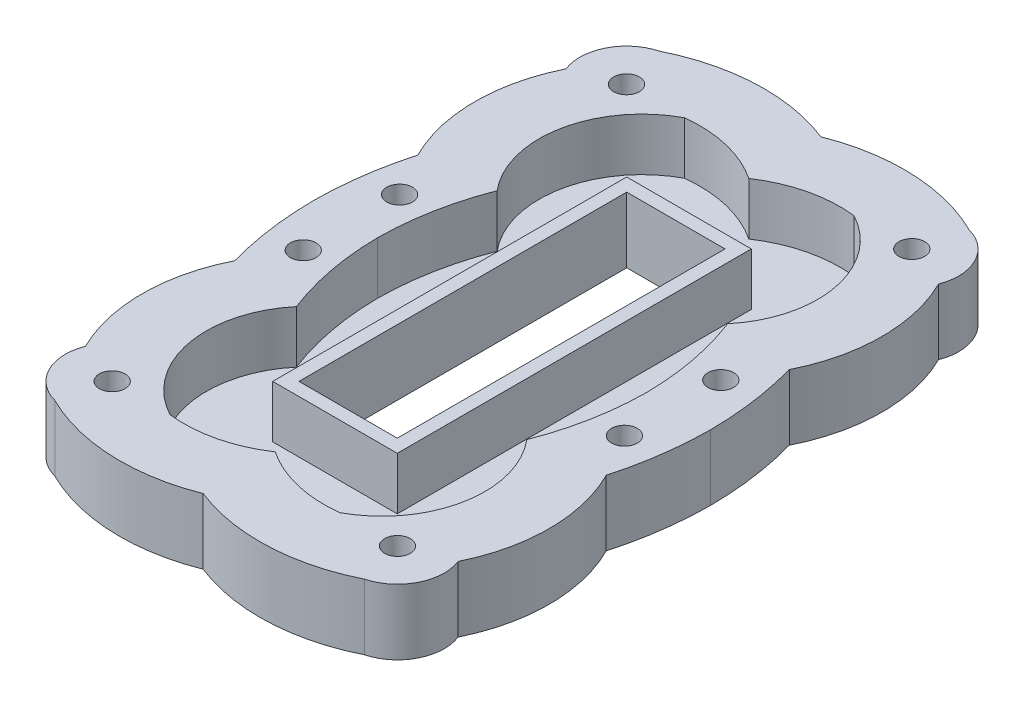
from build123d import *

# Parameters (mm, degrees)
SKETCH1_W           = 19
SKETCH1_H           = 54
BOSS_EXTRUDE4_DEPTH = 2
SKETCH1_8_R         = 1.96
SKETCH1_8_W         = 19
SKETCH1_8_H         = 54
SKETCH1_8_W_2       = 15
SKETCH1_8_H_2       = 50
BOSS_EXTRUDE7_DEPTH = 10


with BuildPart() as part:
    # Sketch1 → Boss-Extrude4 (new body)
    with BuildSketch(Plane(origin=(0, 0, 0), x_dir=(1, 0, 0), z_dir=(0, 1, 0))):
        with BuildLine():
            ThreePointArc((0, 36.123062219), (-6.193274653, 38.828364827), (-12.939793146, 39.228116436))
            ThreePointArc((-12.939793146, 39.228116436), (-20.958488329, 28.375411428), (-17.576524537, 15.31237199))
            ThreePointArc((-17.576524537, 15.31237199), (-19.723741965, 7.787946982), (-20.482290695, 0))
            ThreePointArc((-20.482290695, 0), (-19.723741965, -7.787946982), (-17.576524537, -15.31237199))
            ThreePointArc((-17.576524537, -15.31237199), (-20.958488329, -28.375411428), (-12.939793146, -39.228116436))
            ThreePointArc((-12.939793146, -39.228116436), (-6.193274653, -38.828364827), (0, -36.123062219))
            ThreePointArc((0, -36.123062219), (6.193274653, -38.828364827), (12.939793146, -39.228116436))
            ThreePointArc((12.939793146, -39.228116436), (20.958488329, -28.375411428), (17.576524537, -15.31237199))
            ThreePointArc((17.576524537, -15.31237199), (19.723741965, -7.787946982), (20.482290695, 0))
            ThreePointArc((20.482290695, 0), (19.723741965, 7.787946982), (17.576524537, 15.31237199))
            ThreePointArc((17.576524537, 15.31237199), (20.958488329, 28.375411428), (12.939793146, 39.228116436))
            ThreePointArc((12.939793146, 39.228116436), (6.193274653, 38.828364827), (0, 36.123062219))
        make_face()
        Rectangle(SKETCH1_W, SKETCH1_H, mode=Mode.SUBTRACT)
    extrude(amount=BOSS_EXTRUDE4_DEPTH)

    # Sketch1_8 → Boss-Extrude7 (add)
    # profile 1 of 2: a face of its own
    with BuildSketch(Plane(origin=(0, 0, 0), x_dir=(1, 0, 0), z_dir=(0, 1, 0))):
        with BuildLine():
            ThreePointArc((23.603104913, 46.133139939), (11.906709568, 49.134588213), (0, 47.123463385))
            ThreePointArc((0, 47.123463385), (-11.906709568, 49.134588213), (-23.603104913, 46.133139939))
            ThreePointArc((-23.603104913, 46.133139939), (-28.130450168, 42.466846104), (-28.423306673, 36.648530145))
            ThreePointArc((-28.423306673, 36.648530145), (-31.044925166, 25.293928807), (-28.336730948, 13.959664864))
            ThreePointArc((-28.336730948, 13.959664864), (-29.774673681, 7.044655791), (-30.282467524, 0))
            ThreePointArc((-30.282467524, 0), (-29.774673681, -7.044655791), (-28.336730948, -13.959664864))
            ThreePointArc((-28.336730948, -13.959664864), (-31.044925166, -25.293928807), (-28.423306673, -36.648530145))
            ThreePointArc((-28.423306673, -36.648530145), (-28.130450168, -42.466846104), (-23.603104913, -46.133139939))
            ThreePointArc((-23.603104913, -46.133139939), (-11.906709568, -49.134588213), (0, -47.123463385))
            ThreePointArc((0, -47.123463385), (11.906709568, -49.134588213), (23.603104913, -46.133139939))
            ThreePointArc((23.603104913, -46.133139939), (28.130450168, -42.466846104), (28.423306673, -36.648530145))
            ThreePointArc((28.423306673, -36.648530145), (31.044925166, -25.293928807), (28.336730948, -13.959664864))
            ThreePointArc((28.336730948, -13.959664864), (29.774673681, -7.044655791), (30.282467524, 0))
            ThreePointArc((30.282467524, 0), (29.774673681, 7.044655791), (28.336730948, 13.959664864))
            ThreePointArc((28.336730948, 13.959664864), (31.044925166, 25.293928807), (28.423306673, 36.648530145))
            ThreePointArc((28.423306673, 36.648530145), (28.130450168, 42.466846104), (23.603104913, 46.133139939))
        make_face()
        with Locations((-21.760807675, -39.229711143)):
            Circle(SKETCH1_8_R, mode=Mode.SUBTRACT)
        with Locations((-24.5, -7.35)):
            Circle(SKETCH1_8_R, mode=Mode.SUBTRACT)
        with BuildLine():
            ThreePointArc((-17.576524537, 15.31237199), (-20.958488329, 28.375411428), (-12.939793146, 39.228116436))
            ThreePointArc((-12.939793146, 39.228116436), (-6.193274653, 38.828364827), (0, 36.123062219))
            ThreePointArc((0, 36.123062219), (6.193274653, 38.828364827), (12.939793146, 39.228116436))
            ThreePointArc((12.939793146, 39.228116436), (20.958488329, 28.375411428), (17.576524537, 15.31237199))
            ThreePointArc((17.576524537, 15.31237199), (19.723741965, 7.787946982), (20.482290695, 0))
            ThreePointArc((20.482290695, 0), (19.723741965, -7.787946982), (17.576524537, -15.31237199))
            ThreePointArc((17.576524537, -15.31237199), (20.958488329, -28.375411428), (12.939793146, -39.228116436))
            ThreePointArc((12.939793146, -39.228116436), (6.193274653, -38.828364827), (0, -36.123062219))
            ThreePointArc((0, -36.123062219), (-6.193274653, -38.828364827), (-12.939793146, -39.228116436))
            ThreePointArc((-12.939793146, -39.228116436), (-20.958488329, -28.375411428), (-17.576524537, -15.31237199))
            ThreePointArc((-17.576524537, -15.31237199), (-19.723741965, -7.787946982), (-20.482290695, 0))
            ThreePointArc((-20.482290695, 0), (-19.723741965, 7.787946982), (-17.576524537, 15.31237199))
        make_face(mode=Mode.SUBTRACT)
        with Locations((21.760807675, -39.229711143)):
            Circle(SKETCH1_8_R, mode=Mode.SUBTRACT)
        with Locations((24.5, -7.35)):
            Circle(SKETCH1_8_R, mode=Mode.SUBTRACT)
        with Locations((-24.5, 7.35)):
            Circle(SKETCH1_8_R, mode=Mode.SUBTRACT)
        with Locations((-21.760807675, 39.229711143)):
            Circle(SKETCH1_8_R, mode=Mode.SUBTRACT)
        with Locations((24.5, 7.35)):
            Circle(SKETCH1_8_R, mode=Mode.SUBTRACT)
        with Locations((21.760807675, 39.229711143)):
            Circle(SKETCH1_8_R, mode=Mode.SUBTRACT)
    # profile 2 of 2: a face of its own
    with BuildSketch(Plane(origin=(0, 0, 0), x_dir=(1, 0, 0), z_dir=(0, 1, 0))):
        Rectangle(SKETCH1_8_W, SKETCH1_8_H)
        Rectangle(SKETCH1_8_W_2, SKETCH1_8_H_2, mode=Mode.SUBTRACT)
    extrude(amount=BOSS_EXTRUDE7_DEPTH)


solid = part.part
